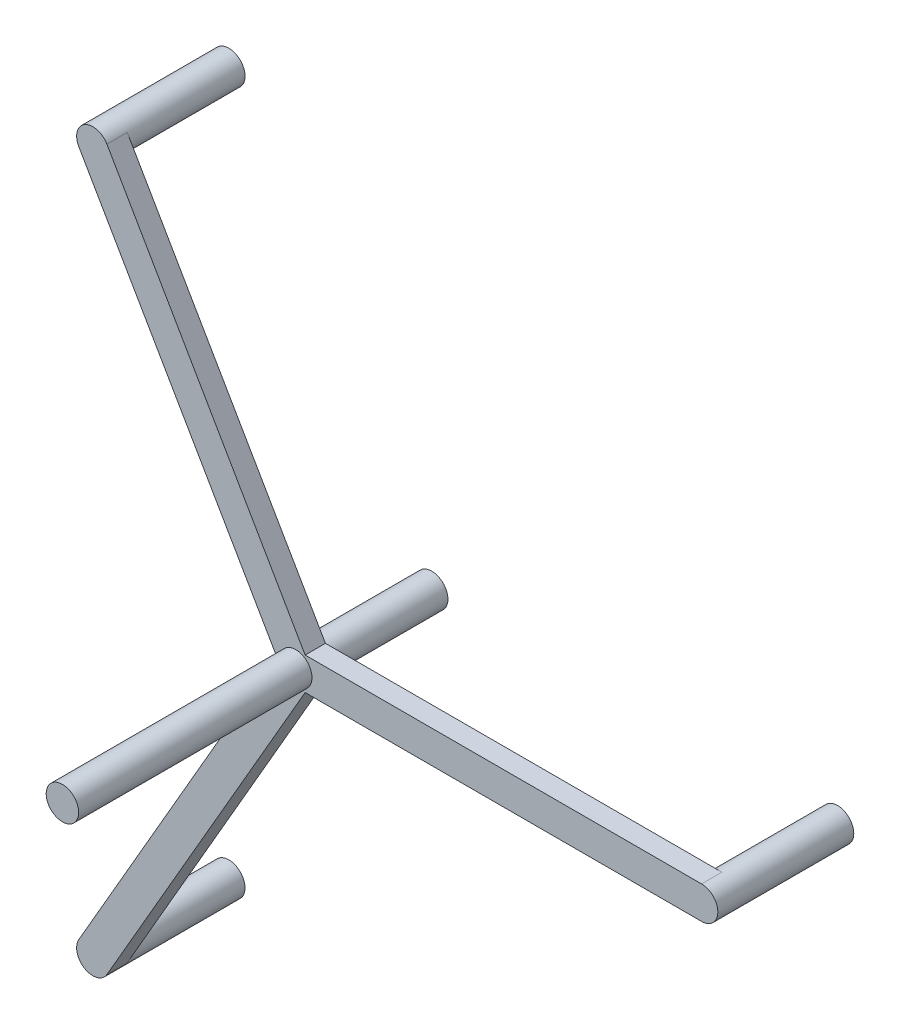
from build123d import *

# Parameters (mm, degrees)
BOSS_EXTRUDE1_DEPTH = 1.25
BOSS_EXTRUDE4_START = 1.25
SKETCH1_5_R         = 2
BOSS_EXTRUDE4_DEPTH = 16.75
BOSS_EXTRUDE5_START = 30
SKETCH1_6_R         = 2
BOSS_EXTRUDE5_DEPTH = 30
CIRPATTERN1_COUNT   = 3


with BuildPart() as part:
    # Sketch1 → Boss-Extrude1 (new, symmetric)
    with BuildSketch(Plane.XY):
        with BuildLine():
            ThreePointArc((0, 2), (2, 0), (0, -2))
            Line((0, -2), (50, -2))
            ThreePointArc((50, -2), (48, 0), (50, 2))
            Line((50, 2), (0, 2))
        make_face()
    boss_extrude1 = extrude(amount=BOSS_EXTRUDE1_DEPTH, both=True)

    # Sketch1_5 → Boss-Extrude4 (add)
    with BuildSketch(Plane.XY.offset(BOSS_EXTRUDE4_START)):
        Circle(SKETCH1_5_R)
        with Locations((50, 0)):
            Circle(SKETCH1_5_R)
    boss_extrude4 = extrude(amount=-BOSS_EXTRUDE4_DEPTH)

    # Sketch1_6 → Boss-Extrude5 (add)
    with BuildSketch(Plane.XY.offset(BOSS_EXTRUDE5_START)):
        Circle(SKETCH1_6_R)
    extrude(amount=-BOSS_EXTRUDE5_DEPTH)

    # CirPattern1: Boss-Extrude1, Boss-Extrude4 ×3 about axis
    cirpattern1_axis = Axis((0, 0, 30), (0, 0, 1))
    add([boss_extrude1.rotate(cirpattern1_axis, i * 360 / CIRPATTERN1_COUNT) for i in range(1, CIRPATTERN1_COUNT)])
    add([boss_extrude4.rotate(cirpattern1_axis, i * 360 / CIRPATTERN1_COUNT) for i in range(1, CIRPATTERN1_COUNT)])


solid = part.part
